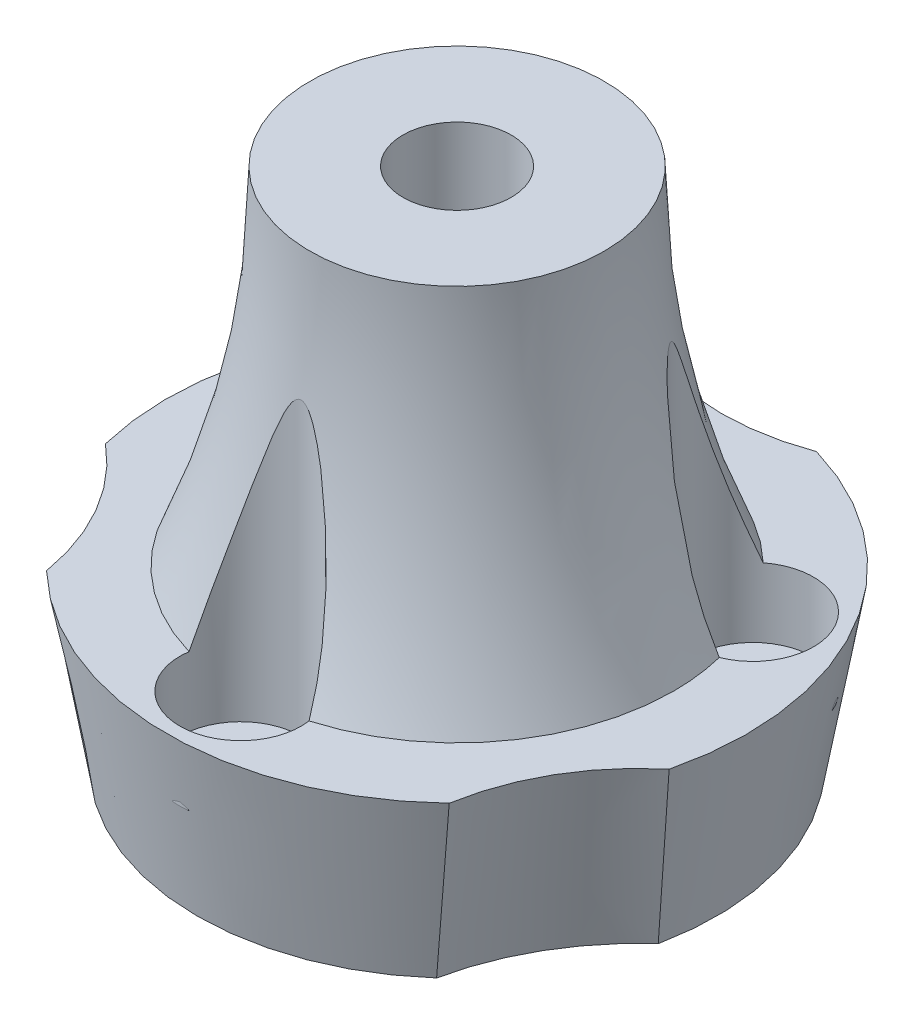
from build123d import *

# Parameters (mm, degrees)
BOSS_EXTRUDE1_DEPTH     = 5.08
BOSS_EXTRUDE1_DRAFT     = -10
SKETCH2_R               = 1.016
CUT_EXTRUDE1_DEPTH      = 14.07065766
SKETCH3_R               = 1.778
CUT_EXTRUDE2_DEPTH      = 2.032
SKETCH4_R               = 4.3815
CUT_EXTRUDE3_DEPTH      = 2.032
CUT_EXTRUDE4_DEPTH      = 10.16
CUT_EXTRUDE4_DEPTH_BACK = 2.032
SKETCH3_2_R             = 1.778
SKETCH7_R               = 1.5875
CUT_EXTRUDE5_DEPTH      = 11.43
SKETCH8_R               = 0.5
CUT_EXTRUDE6_DEPTH      = 20.424039094


with BuildPart() as part:
    # Sketch1 → Boss-Extrude1 (with draft: the straight prism first)
    with BuildSketch(Plane(origin=(0, 0, 0), x_dir=(1, 0, 0), z_dir=(0, 1, 0))):
        with BuildLine():
            ThreePointArc((7.458830017, -1.558927446), (6.599113577, 3.81), (2.379344237, 7.239))
            ThreePointArc((2.379344237, 7.239), (0, 6.858), (-2.379344237, 7.239))
            ThreePointArc((-2.379344237, 7.239), (-6.599113577, 3.81), (-7.458830017, -1.558927446))
            ThreePointArc((-7.458830017, -1.558927446), (-5.939202219, -3.429), (-5.079485779, -5.680072554))
            ThreePointArc((-5.079485779, -5.680072554), (0, -7.62), (5.079485779, -5.680072554))
            ThreePointArc((5.079485779, -5.680072554), (5.939202219, -3.429), (7.458830017, -1.558927446))
        make_face()
    extrude(amount=BOSS_EXTRUDE1_DEPTH)
    # Boss-Extrude1: the draft: its side faces are tilted about the plane it starts from
    boss_extrude1_sides = [part.faces().sort_by_distance(p)[0] for p in [
        (5.939202219, 2.54, 3.429),
        (6.599113577, 2.54, -3.81),
        (0, 2.54, -6.858),
        (-6.599113577, 2.54, -3.81),
        (-5.939202219, 2.54, 3.429),
        (0, 2.54, 7.62),
    ]]
    draft(boss_extrude1_sides, Plane(origin=(0, 0, 0), x_dir=(1, 0, 0), z_dir=(0, 1, 0)), BOSS_EXTRUDE1_DRAFT)

    # Sketch2 → Cut-Extrude1 (cut, through all)
    with BuildSketch(Plane(origin=(0, 5.08, 0), x_dir=(1, 0, 0), z_dir=(0, 1, 0))):
        with Locations((0, -6.35)):
            Circle(SKETCH2_R)
        with Locations((-5.499261314, 3.175)):
            Circle(SKETCH2_R)
        with Locations((5.499261314, 3.175)):
            Circle(SKETCH2_R)
    extrude(amount=-CUT_EXTRUDE1_DEPTH, mode=Mode.SUBTRACT)

    # Sketch3 → Cut-Extrude2 (cut)
    with BuildSketch(Plane(origin=(0, 5.08, 0), x_dir=(1, 0, 0), z_dir=(0, 1, 0))):
        with Locations((0, -6.35)):
            Circle(SKETCH3_R)
        with Locations((-5.499261314, 3.175)):
            Circle(SKETCH3_R)
        with Locations((5.499261314, 3.175)):
            Circle(SKETCH3_R)
    extrude(amount=-CUT_EXTRUDE2_DEPTH, mode=Mode.SUBTRACT)

    # Sketch4 → Cut-Extrude3 (cut)
    with BuildSketch(Plane.XZ):
        Circle(SKETCH4_R)
    extrude(amount=-CUT_EXTRUDE3_DEPTH, mode=Mode.SUBTRACT)

    # Sketch6 → Revolve1 (revolve)
    with BuildSketch(Plane.XY):
        with BuildLine():
            Line((0, 5.08), (0, 15.24))
            Line((0, 15.24), (4.318, 15.24))
            ThreePointArc((4.318, 15.24), (4.830980871, 10.059396174), (6.35, 5.08))
            Line((6.35, 5.08), (0, 5.08))
        make_face()
    revolve(axis=Axis((0, 5.08, 0), (0, 1, 0)))

    # Sketch3_2 → Cut-Extrude4 (cut, two sides: drawn at the far end of the back side and taken through both)
    with BuildSketch(Plane(origin=(0, 5.08, 0), x_dir=(1, 0, 0), z_dir=(0, 1, 0)).offset(-CUT_EXTRUDE4_DEPTH_BACK)):
        with Locations((0, -6.35)):
            Circle(SKETCH3_2_R)
        with Locations((-5.499261314, 3.175)):
            Circle(SKETCH3_2_R)
        with Locations((5.499261314, 3.175)):
            Circle(SKETCH3_2_R)
    extrude(amount=CUT_EXTRUDE4_DEPTH + CUT_EXTRUDE4_DEPTH_BACK, mode=Mode.SUBTRACT)

    # Sketch7 → Cut-Extrude5 (cut)
    with BuildSketch(Plane(origin=(0, 15.24, 0), x_dir=(1, 0, 0), z_dir=(0, 1, 0))):
        Circle(SKETCH7_R)
    extrude(amount=-CUT_EXTRUDE5_DEPTH, mode=Mode.SUBTRACT)

    # Sketch8 → Cut-Extrude6 (cut, through all)
    with BuildSketch(Plane.XY):
        with Locations((0, 12.7)):
            Circle(SKETCH8_R)
    extrude(amount=-CUT_EXTRUDE6_DEPTH, mode=Mode.SUBTRACT)


solid = part.part
